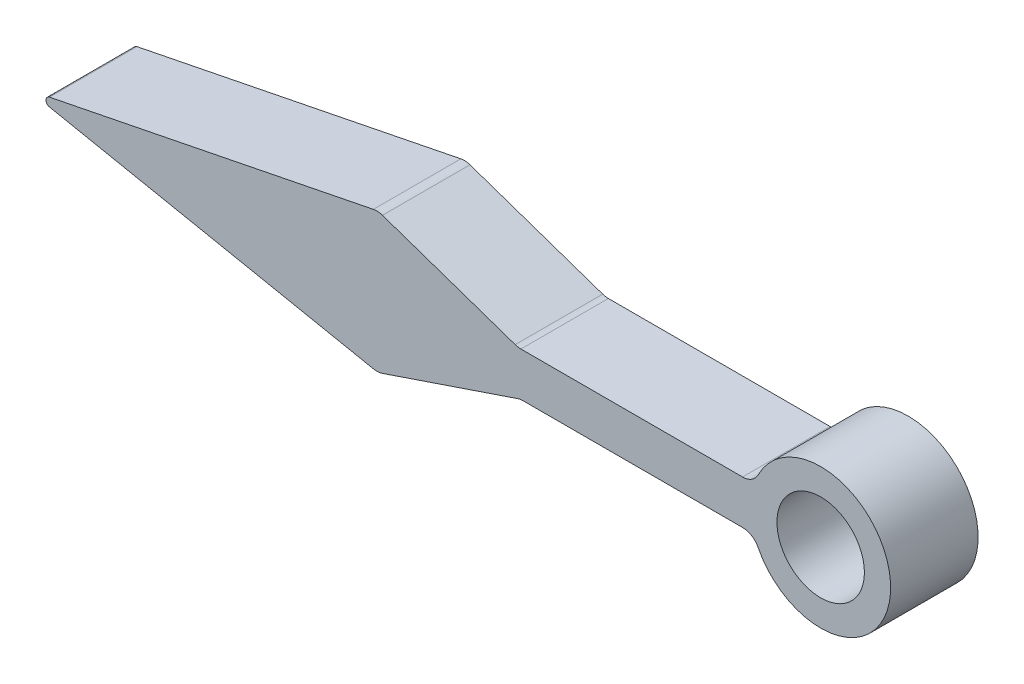
from build123d import *

# Parameters (mm, degrees)
ESQUISSE1_R        = 2.5
BOSS_EXTRU_1_DEPTH = 5
CONG_1_R           = 1
CONG_2_R           = 0.25


with BuildPart() as part:
    # Esquisse1 → Boss.-Extru.1 (new body)
    with BuildSketch(Plane.XY):
        with BuildLine():
            Line((-3.799671038, 1.25), (-17.299671038, 1.25))
            Line((-17.299671038, 1.25), (-25.299671038, 4))
            Line((-25.299671038, 4), (-45.299671038, 0))
            Line((-45.299671038, 0), (-25.299671038, -4))
            Line((-25.299671038, -4), (-17.170505914, -1.25))
            Line((-17.170505914, -1.25), (-3.799671038, -1.25))
            ThreePointArc((-3.799671038, -1.25), (4, 0), (-3.799671038, 1.25))
        make_face()
        Circle(ESQUISSE1_R, mode=Mode.SUBTRACT)
    extrude(amount=BOSS_EXTRU_1_DEPTH)

    # Congé1
    cong_1_edges = [part.edges().sort_by_distance(p)[0] for p in [
        (-25.299671038, 4, 2.5),
        (-17.299671038, 1.25, 2.5),
        (-3.799671038, 1.25, 2.5),
        (-3.799671038, -1.25, 2.5),
        (-17.170505914, -1.25, 2.5),
        (-25.299671038, -4, 2.5),
    ]]
    fillet(cong_1_edges, radius=CONG_1_R)

    # Congé2
    cong_2_edges = [part.edges().sort_by_distance(p)[0] for p in [
        (-45.299671038, 0, 2.5),
    ]]
    fillet(cong_2_edges, radius=CONG_2_R)


solid = part.part
